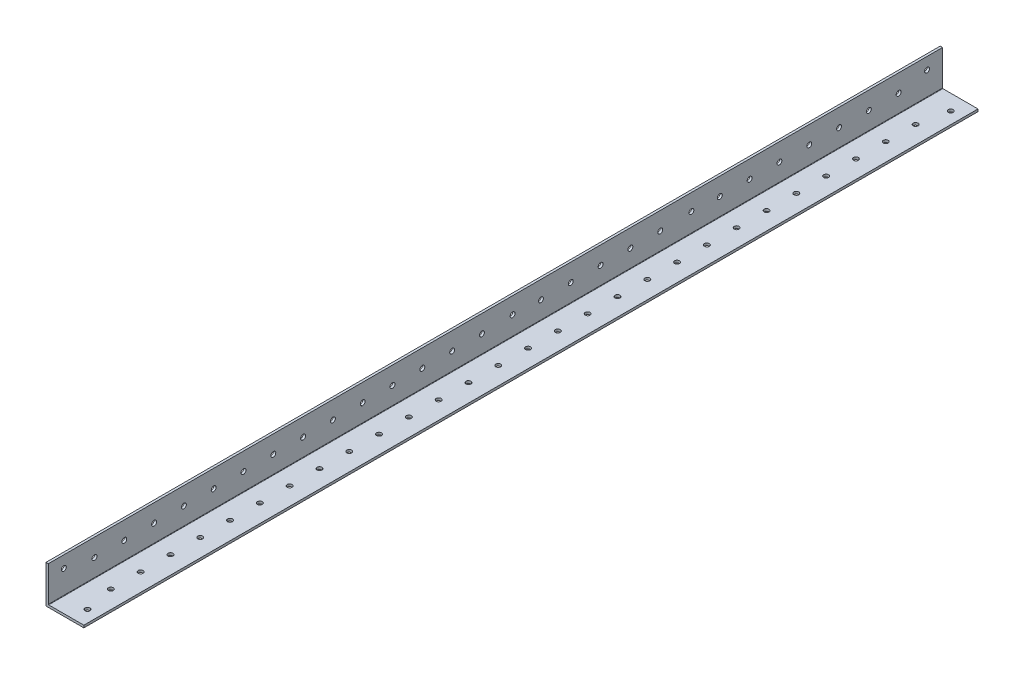
from build123d import *

# Parameters (mm, degrees)
BOSS_EXTRUDE1_DEPTH = 1219.2
FILLET1_R           = 0.254
SKETCH4_W           = 1838.4
SKETCH4_H           = 74.945320812
CUT_EXTRUDE1_DEPTH  = 60
SKETCH5_R           = 1.65
CUT_EXTRUDE2_DEPTH  = 10
SKETCH9_R           = 1.65
CUT_EXTRUDE6_DEPTH  = 60


with BuildPart() as part:
    # Sketch3 → Boss-Extrude1 (new, symmetric)
    with BuildSketch(Plane.XY):
        Polygon((1.5875, 25.4), (0, 25.4), (0, 0), (25.4, 0), (25.4, 1.5875), (1.5875, 1.5875), align=None)
    extrude(amount=BOSS_EXTRUDE1_DEPTH, both=True)

    # Fillet1
    fillet1_edges = [part.edges().sort_by_distance(p)[0] for p in [
        (1.5875, 1.5875, 0),
    ]]
    fillet(fillet1_edges, radius=FILLET1_R)

    # Sketch4 → Cut-Extrude1 (cut)
    with BuildSketch(Plane.ZY):
        with Locations((-300, 37.472660406)):
            Rectangle(SKETCH4_W, SKETCH4_H)
    extrude(amount=-CUT_EXTRUDE1_DEPTH, mode=Mode.SUBTRACT)

    # Sketch5 → Cut-Extrude2 (cut)
    with BuildSketch(Plane(origin=(0, 1.5875, 0), x_dir=(1, 0, 0), z_dir=(0, 1, 0))):
        with Locations(Location((17.4625, -629.5759, 0), (0, 0, 180))):
            Circle(SKETCH5_R)
        with Locations(Location((17.4625, -1208.8241, 0), (0, 0, 180))):
            Circle(SKETCH5_R)
        with Locations(Location((13.49375, -1189.2, 0), (0, 0, 180))):
            Circle(SKETCH5_R)
        with Locations(Location((13.49375, -1169.2, 0), (0, 0, 180))):
            Circle(SKETCH5_R)
        with Locations(Location((13.49375, -1149.2, 0), (0, 0, 180))):
            Circle(SKETCH5_R)
        with Locations(Location((13.49375, -1129.2, 0), (0, 0, 180))):
            Circle(SKETCH5_R)
        with Locations(Location((13.49375, -1109.2, 0), (0, 0, 180))):
            Circle(SKETCH5_R)
        with Locations(Location((13.49375, -1089.2, 0), (0, 0, 180))):
            Circle(SKETCH5_R)
        with Locations(Location((13.49375, -1069.2, 0), (0, 0, 180))):
            Circle(SKETCH5_R)
        with Locations(Location((13.49375, -1049.2, 0), (0, 0, 180))):
            Circle(SKETCH5_R)
        with Locations(Location((13.49375, -1029.2, 0), (0, 0, 180))):
            Circle(SKETCH5_R)
        with Locations(Location((13.49375, -1009.2, 0), (0, 0, 180))):
            Circle(SKETCH5_R)
        with Locations(Location((13.49375, -989.2, 0), (0, 0, 180))):
            Circle(SKETCH5_R)
        with Locations(Location((13.49375, -969.2, 0), (0, 0, 180))):
            Circle(SKETCH5_R)
        with Locations(Location((13.49375, -949.2, 0), (0, 0, 180))):
            Circle(SKETCH5_R)
        with Locations(Location((13.49375, -929.2, 0), (0, 0, 180))):
            Circle(SKETCH5_R)
        with Locations(Location((13.49375, -909.2, 0), (0, 0, 180))):
            Circle(SKETCH5_R)
        with Locations(Location((13.49375, -889.2, 0), (0, 0, 180))):
            Circle(SKETCH5_R)
        with Locations(Location((13.49375, -869.2, 0), (0, 0, 180))):
            Circle(SKETCH5_R)
        with Locations(Location((13.49375, -849.2, 0), (0, 0, 180))):
            Circle(SKETCH5_R)
        with Locations(Location((13.49375, -829.2, 0), (0, 0, 180))):
            Circle(SKETCH5_R)
        with Locations(Location((13.49375, -809.2, 0), (0, 0, 180))):
            Circle(SKETCH5_R)
        with Locations(Location((13.49375, -789.2, 0), (0, 0, 180))):
            Circle(SKETCH5_R)
        with Locations(Location((13.49375, -769.2, 0), (0, 0, 180))):
            Circle(SKETCH5_R)
        with Locations(Location((13.49375, -749.2, 0), (0, 0, 180))):
            Circle(SKETCH5_R)
        with Locations(Location((13.49375, -729.2, 0), (0, 0, 180))):
            Circle(SKETCH5_R)
        with Locations(Location((13.49375, -709.2, 0), (0, 0, 180))):
            Circle(SKETCH5_R)
        with Locations(Location((13.49375, -689.2, 0), (0, 0, 180))):
            Circle(SKETCH5_R)
        with Locations(Location((13.49375, -669.2, 0), (0, 0, 180))):
            Circle(SKETCH5_R)
        with Locations(Location((13.49375, -649.2, 0), (0, 0, 180))):
            Circle(SKETCH5_R)
    extrude(amount=-CUT_EXTRUDE2_DEPTH, mode=Mode.SUBTRACT)

    # Sketch9 → Cut-Extrude6 (cut)
    with BuildSketch(Plane(origin=(1.5875, 0, 0), x_dir=(0, 0, -1), z_dir=(1, 0, 0))):
        with Locations((-629.5759, 17.4625)):
            Circle(SKETCH9_R)
        with Locations((-1208.8241, 17.463)):
            Circle(SKETCH9_R)
        with Locations((-1188.258925, 13.49375)):
            Circle(SKETCH9_R)
        with Locations((-1168.258925, 13.49375)):
            Circle(SKETCH9_R)
        with Locations((-1148.258925, 13.49375)):
            Circle(SKETCH9_R)
        with Locations((-1128.258925, 13.49375)):
            Circle(SKETCH9_R)
        with Locations((-1108.258925, 13.49375)):
            Circle(SKETCH9_R)
        with Locations((-1088.258925, 13.49375)):
            Circle(SKETCH9_R)
        with Locations((-1068.258925, 13.49375)):
            Circle(SKETCH9_R)
        with Locations((-1048.258925, 13.49375)):
            Circle(SKETCH9_R)
        with Locations((-1028.258925, 13.49375)):
            Circle(SKETCH9_R)
        with Locations((-1008.258925, 13.49375)):
            Circle(SKETCH9_R)
        with Locations((-988.258925, 13.49375)):
            Circle(SKETCH9_R)
        with Locations((-968.258925, 13.49375)):
            Circle(SKETCH9_R)
        with Locations((-948.258925, 13.49375)):
            Circle(SKETCH9_R)
        with Locations((-928.258925, 13.49375)):
            Circle(SKETCH9_R)
        with Locations((-787.69375, 14.2875)):
            Circle(SKETCH9_R)
        with Locations((-907.69375, 14.2875)):
            Circle(SKETCH9_R)
        with Locations((-648.634825, 13.49375)):
            Circle(SKETCH9_R)
        with Locations((-668.634825, 13.49375)):
            Circle(SKETCH9_R)
        with Locations((-688.634825, 13.49375)):
            Circle(SKETCH9_R)
        with Locations((-708.634825, 13.49375)):
            Circle(SKETCH9_R)
        with Locations((-728.634825, 13.49375)):
            Circle(SKETCH9_R)
        with Locations((-748.634825, 13.49375)):
            Circle(SKETCH9_R)
        with Locations((-768.634825, 13.49375)):
            Circle(SKETCH9_R)
        with Locations((-808.634825, 13.49375)):
            Circle(SKETCH9_R)
        with Locations((-828.634825, 13.49375)):
            Circle(SKETCH9_R)
        with Locations((-848.634825, 13.49375)):
            Circle(SKETCH9_R)
        with Locations((-868.634825, 13.49375)):
            Circle(SKETCH9_R)
        with Locations((-888.634825, 13.49375)):
            Circle(SKETCH9_R)
    extrude(amount=-CUT_EXTRUDE6_DEPTH, mode=Mode.SUBTRACT)


solid = part.part
